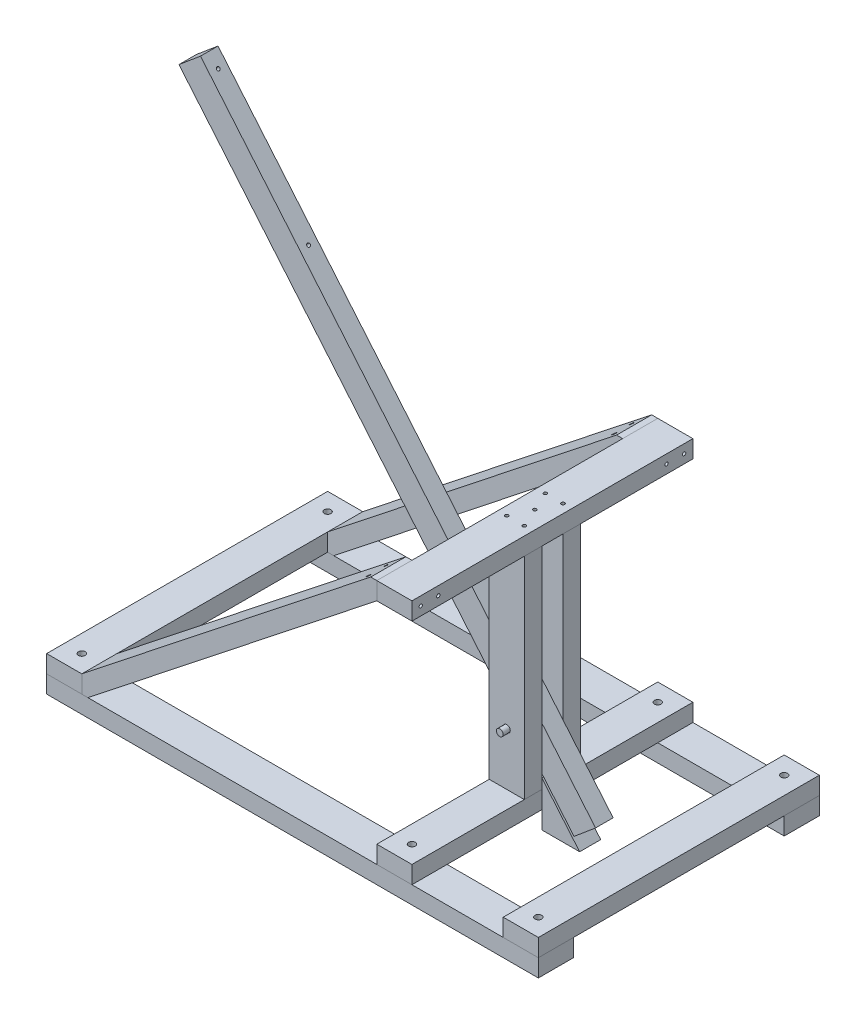
from build123d import *

# Parameters (mm, degrees)
CROQUIS2_W                   = 700
CROQUIS2_H                   = 50
SALIENTE_EXTRUIR1_DEPTH      = 25
SALIENTE_EXTRUIR1_2_DEPTH    = 25
CROQUIS3_W                   = 50
CROQUIS3_H                   = 400
SALIENTE_EXTRUIR2_DEPTH      = 25
SALIENTE_EXTRUIR2_2_DEPTH    = 25
SALIENTE_EXTRUIR2_3_DEPTH    = 25
CROQUIS5_W                   = 50
CROQUIS5_H                   = 25
SALIENTE_EXTRUIR3_DEPTH      = 300
SALIENTE_EXTRUIR3_2_DEPTH    = 300
CROQUIS6_W                   = 50
CROQUIS6_H                   = 400
SALIENTE_EXTRUIR4_DEPTH      = 25
SALIENTE_EXTRUIR5_DEPTH      = 50
SALIENTE_EXTRUIR6_DEPTH      = 15
SALIENTE_EXTRUIR6_DEPTH_BACK = 15
CROQUIS9_R                   = 5
SALIENTE_EXTRUIR7_DEPTH      = 12.5
SALIENTE_EXTRUIR7_DEPTH_BACK = 12.5
CROQUIS10_R                  = 5
CORTAR_EXTRUIR1_DEPTH        = 80
CROQUIS11_R                  = 4.7625
SALIENTE_EXTRUIR8_DEPTH      = 50
SALIENTE_EXTRUIR8_DEPTH_BACK = 52.5
CROQUIS12_R                  = 4.7625
CORTAR_EXTRUIR2_DEPTH        = 50
CORTAR_EXTRUIR3_START        = -77.518369
CROQUIS13_R                  = 2.38125
CORTAR_EXTRUIR3_DEPTH        = 77.518369
CORTAR_EXTRUIR4_START        = -77.518369
CROQUIS14_R                  = 2.38125
CORTAR_EXTRUIR4_DEPTH        = 77.518369
CORTAR_EXTRUIR5_START        = -74.311178
CROQUIS15_R                  = 2.38125
CORTAR_EXTRUIR5_DEPTH        = 74.311178
CROQUIS16_R                  = 2.38125
CORTAR_EXTRUIR6_DEPTH        = 40
CROQUIS17_R                  = 2.38125
CORTAR_EXTRUIR7_DEPTH        = 70
CROQUIS18_R                  = 2.38125
CORTAR_EXTRUIR8_DEPTH        = 70


with BuildPart() as part:
    # Croquis2 → Saliente-Extruir1 (new body)
    with BuildSketch(Plane(origin=(0, 0, 0), x_dir=(1, 0, 0), z_dir=(0, 1, 0))):
        with Locations((0, 175)):
            Rectangle(CROQUIS2_W, CROQUIS2_H)
    extrude(amount=SALIENTE_EXTRUIR1_DEPTH)


with BuildPart() as body_2:
    # Croquis2 → Saliente-Extruir1 2 (new body)
    with BuildSketch(Plane(origin=(0, 0, 0), x_dir=(1, 0, 0), z_dir=(0, 1, 0))):
        with Locations((0, -175)):
            Rectangle(CROQUIS2_W, CROQUIS2_H)
    extrude(amount=SALIENTE_EXTRUIR1_2_DEPTH)


with BuildPart() as body_3:
    # Croquis3 → Saliente-Extruir2 (new body)
    with BuildSketch(Plane(origin=(0, 25, 0), x_dir=(1, 0, 0), z_dir=(0, 1, 0))):
        with Locations((-325, 0)):
            Rectangle(CROQUIS3_W, CROQUIS3_H)
    extrude(amount=SALIENTE_EXTRUIR2_DEPTH)


with BuildPart() as body_4:
    # Croquis3 → Saliente-Extruir2 2 (new body)
    with BuildSketch(Plane(origin=(0, 25, 0), x_dir=(1, 0, 0), z_dir=(0, 1, 0))):
        with Locations((325, 0)):
            Rectangle(CROQUIS3_W, CROQUIS3_H)
    extrude(amount=SALIENTE_EXTRUIR2_2_DEPTH)


with BuildPart() as body_5:
    # Croquis3 → Saliente-Extruir2 3 (new body)
    with BuildSketch(Plane(origin=(0, 25, 0), x_dir=(1, 0, 0), z_dir=(0, 1, 0))):
        with Locations((145, 0)):
            Rectangle(CROQUIS3_W, CROQUIS3_H)
    extrude(amount=SALIENTE_EXTRUIR2_3_DEPTH)


with BuildPart() as body_6:
    # Croquis5 → Saliente-Extruir3 (new body)
    with BuildSketch(Plane(origin=(0, 50, 0), x_dir=(1, 0, 0), z_dir=(0, 1, 0))):
        with Locations((145, 27.5)):
            Rectangle(CROQUIS5_W, CROQUIS5_H)
    extrude(amount=SALIENTE_EXTRUIR3_DEPTH)


with BuildPart() as body_7:
    # Croquis5 → Saliente-Extruir3 2 (new body)
    with BuildSketch(Plane(origin=(0, 50, 0), x_dir=(1, 0, 0), z_dir=(0, 1, 0))):
        with Locations((145, -27.5)):
            Rectangle(CROQUIS5_W, CROQUIS5_H)
    extrude(amount=SALIENTE_EXTRUIR3_2_DEPTH)


with BuildPart() as body_8:
    # Croquis6 → Saliente-Extruir4 (new body)
    with BuildSketch(Plane(origin=(0, 350, 0), x_dir=(1, 0, 0), z_dir=(0, 1, 0))):
        with Locations((145, 0)):
            Rectangle(CROQUIS6_W, CROQUIS6_H)
    extrude(amount=SALIENTE_EXTRUIR4_DEPTH)


with BuildPart() as body_9:
    # Croquis7 → Saliente-Extruir5 (new body)
    with BuildSketch(Plane.XY.offset(200)):
        Polygon((-300, 50), (-300, 25), (-291.315117815, 25), (120, 350), (120, 375), (111.315117815, 375), align=None)
    extrude(amount=-SALIENTE_EXTRUIR5_DEPTH)


with BuildPart() as body_10:
    # Simetría2: mirrored copy
    add(body_9.part.mirror(Plane.XY))


with BuildPart() as body_11:
    # Croquis8 → Saliente-Extruir6 (new body, two sides)
    with BuildSketch(Plane.XY) as saliente_extruir6_sk:
        Polygon((170, 64.091683648), (223.779308111, 0), (170, 0), align=None)
    extrude(amount=SALIENTE_EXTRUIR6_DEPTH)
    extrude(saliente_extruir6_sk.sketch, amount=-SALIENTE_EXTRUIR6_DEPTH_BACK)


with BuildPart() as body_12:
    # Croquis9 → Saliente-Extruir7 (new body, two sides)
    with BuildSketch(Plane.XY) as saliente_extruir7_sk:
        Polygon((-349.197658079, 682.84735793), (-318.555880354, 708.558862317), (243.932340446, 38.211504387), (213.290562721, 12.5), align=None)
        with Locations((145, 125)):
            Circle(CROQUIS9_R, mode=Mode.SUBTRACT)
    extrude(amount=SALIENTE_EXTRUIR7_DEPTH)
    extrude(saliente_extruir7_sk.sketch, amount=-SALIENTE_EXTRUIR7_DEPTH_BACK)

    # Croquis16 → Cortar-Extruir6 (cut)
    with BuildSketch(Plane(origin=(161.960866306, 135.901303183, 0), x_dir=(0, 0, -1), z_dir=(0.766044443, 0.64278761, 0))):
        with Locations(Location((0, 727.551351985, 0), (0, 0, 90))):  # turned: the seam where the file's is
            Circle(CROQUIS16_R)
        with Locations(Location((0, 527.551351985, 0), (0, 0, 90))):  # turned: the seam where the file's is
            Circle(CROQUIS16_R)
    extrude(amount=-CORTAR_EXTRUIR6_DEPTH, mode=Mode.SUBTRACT)


with BuildPart() as cortar_extruir1_tool:
    # Croquis10 → Cortar-Extruir1 (new body)
    with BuildSketch(Plane.XY.offset(40)):
        with Locations((145, 125)):
            Circle(CROQUIS10_R)
    extrude(amount=-CORTAR_EXTRUIR1_DEPTH)


with BuildPart() as body_6_1:
    add(body_6.part)

    # Cortar-Extruir1: cut by cortar_extruir1_tool
    add(cortar_extruir1_tool.part, mode=Mode.SUBTRACT)


with BuildPart() as body_7_1:
    add(body_7.part)

    # Cortar-Extruir1: cut by cortar_extruir1_tool
    add(cortar_extruir1_tool.part, mode=Mode.SUBTRACT)


with BuildPart() as body_13:
    # Croquis11 → Saliente-Extruir8 (new body, two sides)
    with BuildSketch(Plane.XY) as saliente_extruir8_sk:
        with Locations(Location((145, 125, 0), (0, 0, 180))):  # turned: the seam where the file's is
            Circle(CROQUIS11_R)
    extrude(amount=SALIENTE_EXTRUIR8_DEPTH)
    extrude(saliente_extruir8_sk.sketch, amount=-SALIENTE_EXTRUIR8_DEPTH_BACK)


with BuildPart() as cortar_extruir2_tool:
    # Croquis12 → Cortar-Extruir2 (new body)
    with BuildSketch(Plane(origin=(0, 50, 0), x_dir=(1, 0, 0), z_dir=(0, 1, 0))):
        with Locations(Location((-325, 175, 0), (0, 0, 270))):  # turned: the seam where the file's is
            Circle(CROQUIS12_R)
        with Locations(Location((-325, -175, 0), (0, 0, 270))):  # turned: the seam where the file's is
            Circle(CROQUIS12_R)
        with Locations(Location((325, -175, 0), (0, 0, 270))):  # turned: the seam where the file's is
            Circle(CROQUIS12_R)
        with Locations(Location((325, 175, 0), (0, 0, 270))):  # turned: the seam where the file's is
            Circle(CROQUIS12_R)
        with Locations(Location((145, 175, 0), (0, 0, 270))):  # turned: the seam where the file's is
            Circle(CROQUIS12_R)
        with Locations(Location((145, -175, 0), (0, 0, 270))):  # turned: the seam where the file's is
            Circle(CROQUIS12_R)
    extrude(amount=-CORTAR_EXTRUIR2_DEPTH)


with BuildPart() as part_1:
    add(part.part)

    # Cortar-Extruir2: cut by cortar_extruir2_tool
    add(cortar_extruir2_tool.part, mode=Mode.SUBTRACT)


with BuildPart() as body_2_1:
    add(body_2.part)

    # Cortar-Extruir2: cut by cortar_extruir2_tool
    add(cortar_extruir2_tool.part, mode=Mode.SUBTRACT)


with BuildPart() as body_3_1:
    add(body_3.part)

    # Cortar-Extruir2: cut by cortar_extruir2_tool
    add(cortar_extruir2_tool.part, mode=Mode.SUBTRACT)


with BuildPart() as body_4_1:
    add(body_4.part)

    # Cortar-Extruir2: cut by cortar_extruir2_tool
    add(cortar_extruir2_tool.part, mode=Mode.SUBTRACT)


with BuildPart() as body_5_1:
    add(body_5.part)

    # Cortar-Extruir2: cut by cortar_extruir2_tool
    add(cortar_extruir2_tool.part, mode=Mode.SUBTRACT)


with BuildPart() as cortar_extruir3_tool:
    # Croquis13 → Cortar-Extruir3 (new body)
    with BuildSketch(Plane(origin=(170, 0, 0), x_dir=(0, 0, -1), z_dir=(1, 0, 0)).offset(CORTAR_EXTRUIR3_START)):
        with Locations(Location((162.5, 362.5, 0), (0, 0, 90))):  # turned: the seam where the file's is
            Circle(CROQUIS13_R)
        with Locations(Location((187.5, 362.5, 0), (0, 0, 90))):  # turned: the seam where the file's is
            Circle(CROQUIS13_R)
        with Locations(Location((-187.5, 362.5, 0), (0, 0, 90))):  # turned: the seam where the file's is
            Circle(CROQUIS13_R)
        with Locations(Location((-162.5, 362.5, 0), (0, 0, 90))):  # turned: the seam where the file's is
            Circle(CROQUIS13_R)
    extrude(amount=CORTAR_EXTRUIR3_DEPTH)


with BuildPart() as body_8_1:
    add(body_8.part)

    # Cortar-Extruir3: cut by cortar_extruir3_tool
    add(cortar_extruir3_tool.part, mode=Mode.SUBTRACT)


with BuildPart() as body_9_1:
    add(body_9.part)

    # Cortar-Extruir3: cut by cortar_extruir3_tool
    add(cortar_extruir3_tool.part, mode=Mode.SUBTRACT)


with BuildPart() as body_10_1:
    add(body_10.part)

    # Cortar-Extruir3: cut by cortar_extruir3_tool
    add(cortar_extruir3_tool.part, mode=Mode.SUBTRACT)


with BuildPart() as cortar_extruir4_tool:
    # Croquis14 → Cortar-Extruir4 (new body)
    with BuildSketch(Plane.ZY.offset(350).offset(CORTAR_EXTRUIR4_START)):
        with Locations((187.5, 37.5)):
            Circle(CROQUIS14_R)
        with Locations((162.5, 37.5)):
            Circle(CROQUIS14_R)
        with Locations((-187.5, 37.5)):
            Circle(CROQUIS14_R)
        with Locations((-162.5, 37.5)):
            Circle(CROQUIS14_R)
    extrude(amount=CORTAR_EXTRUIR4_DEPTH)


with BuildPart() as body_3_2:
    add(body_3_1.part)

    # Cortar-Extruir4: cut by cortar_extruir4_tool
    add(cortar_extruir4_tool.part, mode=Mode.SUBTRACT)


with BuildPart() as body_9_2:
    add(body_9_1.part)

    # Cortar-Extruir4: cut by cortar_extruir4_tool
    add(cortar_extruir4_tool.part, mode=Mode.SUBTRACT)


with BuildPart() as body_10_2:
    add(body_10_1.part)

    # Cortar-Extruir4: cut by cortar_extruir4_tool
    add(cortar_extruir4_tool.part, mode=Mode.SUBTRACT)


with BuildPart() as cortar_extruir5_tool:
    # Croquis15 → Cortar-Extruir5 (new body)
    with BuildSketch(Plane.ZY.offset(-120).offset(CORTAR_EXTRUIR5_START)):
        with Locations(Location((-7.5, 37.5, 0), (0, 0, 270))):  # turned: the seam where the file's is
            Circle(CROQUIS15_R)
        with Locations(Location((7.5, 37.5, 0), (0, 0, 270))):  # turned: the seam where the file's is
            Circle(CROQUIS15_R)
    extrude(amount=CORTAR_EXTRUIR5_DEPTH)


with BuildPart() as body_11_1:
    add(body_11.part)

    # Cortar-Extruir5: cut by cortar_extruir5_tool
    add(cortar_extruir5_tool.part, mode=Mode.SUBTRACT)


with BuildPart() as body_5_2:
    add(body_5_1.part)

    # Cortar-Extruir5: cut by cortar_extruir5_tool
    add(cortar_extruir5_tool.part, mode=Mode.SUBTRACT)


with BuildPart() as cortar_extruir7_tool:
    # Croquis17 → Cortar-Extruir7 (new body)
    with BuildSketch(Plane.XZ.offset(-25)):
        with Locations(Location((132.5, 27.5, 0), (0, 0, 270))):  # turned: the seam where the file's is
            Circle(CROQUIS17_R)
        with Locations(Location((157.5, 27.5, 0), (0, 0, 270))):  # turned: the seam where the file's is
            Circle(CROQUIS17_R)
        with Locations(Location((132.5, -27.5, 0), (0, 0, 270))):  # turned: the seam where the file's is
            Circle(CROQUIS17_R)
        with Locations(Location((157.5, -27.5, 0), (0, 0, 270))):  # turned: the seam where the file's is
            Circle(CROQUIS17_R)
    extrude(amount=-CORTAR_EXTRUIR7_DEPTH)


with BuildPart() as body_5_3:
    add(body_5_2.part)

    # Cortar-Extruir7: cut by cortar_extruir7_tool
    add(cortar_extruir7_tool.part, mode=Mode.SUBTRACT)


with BuildPart() as body_6_2:
    add(body_6_1.part)

    # Cortar-Extruir7: cut by cortar_extruir7_tool
    add(cortar_extruir7_tool.part, mode=Mode.SUBTRACT)


with BuildPart() as body_7_2:
    add(body_7_1.part)

    # Cortar-Extruir7: cut by cortar_extruir7_tool
    add(cortar_extruir7_tool.part, mode=Mode.SUBTRACT)


with BuildPart() as cortar_extruir8_tool:
    # Croquis18 → Cortar-Extruir8 (new body)
    with BuildSketch(Plane(origin=(0, 375, 0), x_dir=(1, 0, 0), z_dir=(0, 1, 0))):
        with Locations(Location((132.5, -27.5, 0), (0, 0, 270))):  # turned: the seam where the file's is
            Circle(CROQUIS18_R)
        with Locations(Location((157.5, -27.5, 0), (0, 0, 270))):  # turned: the seam where the file's is
            Circle(CROQUIS18_R)
        with Locations(Location((132.5, 27.5, 0), (0, 0, 270))):  # turned: the seam where the file's is
            Circle(CROQUIS18_R)
        with Locations(Location((157.5, 27.5, 0), (0, 0, 270))):  # turned: the seam where the file's is
            Circle(CROQUIS18_R)
        with Locations(Location((145, 0, 0), (0, 0, 270))):  # turned: the seam where the file's is
            Circle(CROQUIS18_R)
    extrude(amount=-CORTAR_EXTRUIR8_DEPTH)


with BuildPart() as body_6_3:
    add(body_6_2.part)

    # Cortar-Extruir8: cut by cortar_extruir8_tool
    add(cortar_extruir8_tool.part, mode=Mode.SUBTRACT)


with BuildPart() as body_7_3:
    add(body_7_2.part)

    # Cortar-Extruir8: cut by cortar_extruir8_tool
    add(cortar_extruir8_tool.part, mode=Mode.SUBTRACT)


with BuildPart() as body_8_2:
    add(body_8_1.part)

    # Cortar-Extruir8: cut by cortar_extruir8_tool
    add(cortar_extruir8_tool.part, mode=Mode.SUBTRACT)


solid = Compound([body_12.part, body_13.part, part_1.part, body_2_1.part, body_4_1.part, body_3_2.part, body_9_2.part, body_10_2.part, body_11_1.part, body_5_3.part, body_6_3.part, body_7_3.part, body_8_2.part])
